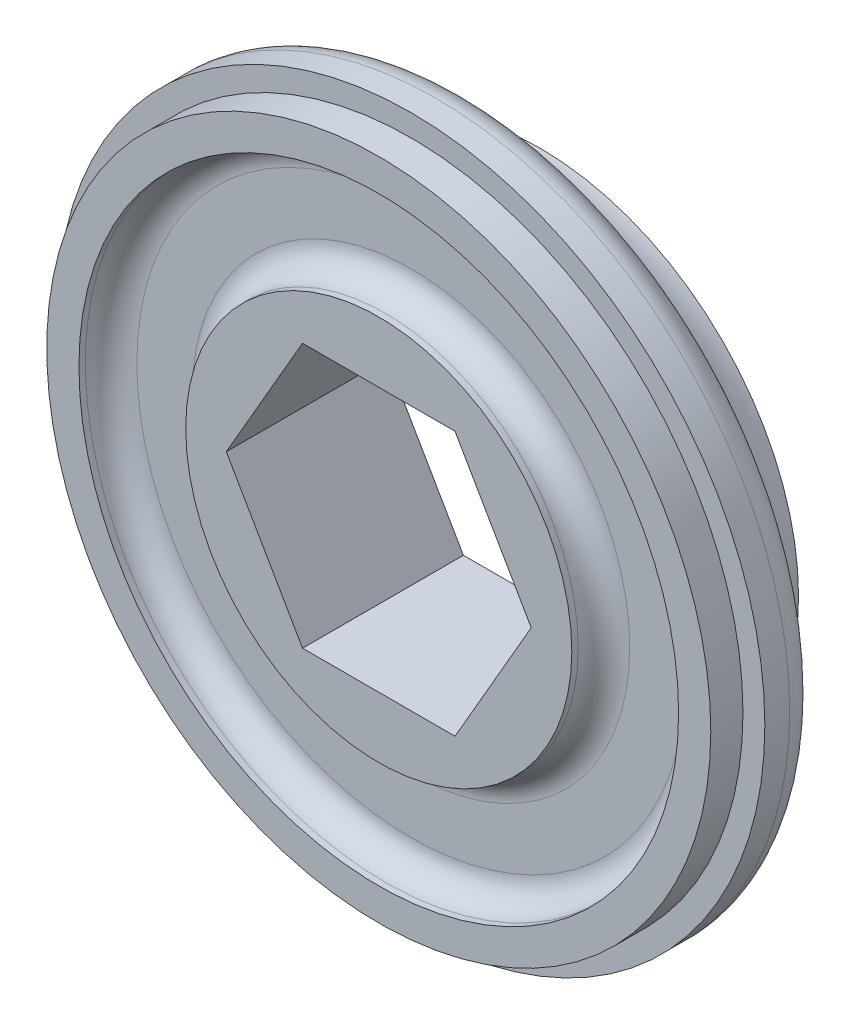
from build123d import *

# Parameters (mm, degrees)
SKETCH1_R                         = 17.4625
HEX_AXEL_CUTOUT_OUTSIDE_RIM_DEPTH = 15.875
SKETCH3_R                         = 19.05
SKETCH3_R_2                       = 16.383
PIPE_STEP_DEPTH                   = 1.5875
SKETCH5_R                         = 14.7955
SKETCH5_R_2                       = 9.525
SPOKE_STEP_DEPTH                  = 1.5875
FILLET1_R                         = 1.27
FILLET2_R                         = 1.5875
SKETCH7_W                         = 50.409195303
SKETCH7_H                         = 73.287011446
MIDCUT_DEPTH                      = 8.9375


with BuildPart() as part:
    # Sketch1 → Hex Axel Cutout & Outside Rim (new body)
    with BuildSketch(Plane.XY):
        Circle(SKETCH1_R)
        Polygon((-7.522989478, 0), (-3.761494739, -6.5151), (3.761494739, -6.5151), (7.522989478, 0), (3.761494739, 6.5151), (-3.761494739, 6.5151), align=None, mode=Mode.SUBTRACT)
    extrude(amount=HEX_AXEL_CUTOUT_OUTSIDE_RIM_DEPTH)

    # Sketch3 → Pipe Step (cut)
    with BuildSketch(Plane.XY.offset(15.875)):
        Circle(SKETCH3_R)
        Circle(SKETCH3_R_2, mode=Mode.SUBTRACT)
    pipe_step = extrude(amount=-PIPE_STEP_DEPTH, mode=Mode.SUBTRACT)

    # Step Mirror: Pipe Step across plane
    add(pipe_step.mirror(Plane.XY.offset(7.9375)), mode=Mode.SUBTRACT)

    # Sketch4 → Poly Cord Groove (revolve, cut)
    with BuildSketch(Plane(origin=(0, 0, 0), x_dir=(0, 0, -1), z_dir=(1, 0, 0))):
        with BuildLine():
            Line((-4.3815, 16.331738244), (-4.3815, 17.4625))
            Line((-4.3815, 17.4625), (-11.4935, 17.4625))
            Line((-11.4935, 17.4625), (-11.4935, 16.331738244))
            ThreePointArc((-11.4935, 16.331738244), (-7.9375, 12.775738244), (-4.3815, 16.331738244))
        make_face()
    revolve(axis=Axis((0, 0, 14.2875), (0, 0, -1)), mode=Mode.SUBTRACT)

    # Sketch5 → Spoke Step (cut)
    with BuildSketch(Plane(origin=(0, 0, 0), x_dir=(-1, 0, 0), z_dir=(0, 0, -1))):
        Circle(SKETCH5_R)
        Circle(SKETCH5_R_2, mode=Mode.SUBTRACT)
    spoke_step = extrude(amount=-SPOKE_STEP_DEPTH, mode=Mode.SUBTRACT)

    # Spoke Step Mirror: Spoke Step across plane
    add(spoke_step.mirror(Plane.XY.offset(7.9375)), mode=Mode.SUBTRACT)

    # Fillet1
    fillet1_edges = [part.edges().sort_by_distance(p)[0] for p in [
        (14.7955, 0, 1.5875),
        (9.525, 0, 1.5875),
        (14.7955, 0, 14.2875),
        (9.525, 0, 14.2875),
    ]]
    fillet(fillet1_edges, radius=FILLET1_R)

    # Fillet2
    fillet2_edges = [part.edges().sort_by_distance(p)[0] for p in [
        (-17.4625, 0, 4.3815),
        (-17.4625, 0, 11.4935),
    ]]
    fillet(fillet2_edges, radius=FILLET2_R)

    # Sketch7 → MidCut (cut, through all)
    with BuildSketch(Plane.XY.offset(7.9375)):
        with Locations((-1.207308933, -3.38321392)):
            Rectangle(SKETCH7_W, SKETCH7_H)
    extrude(amount=-MIDCUT_DEPTH, mode=Mode.SUBTRACT)


solid = part.part
